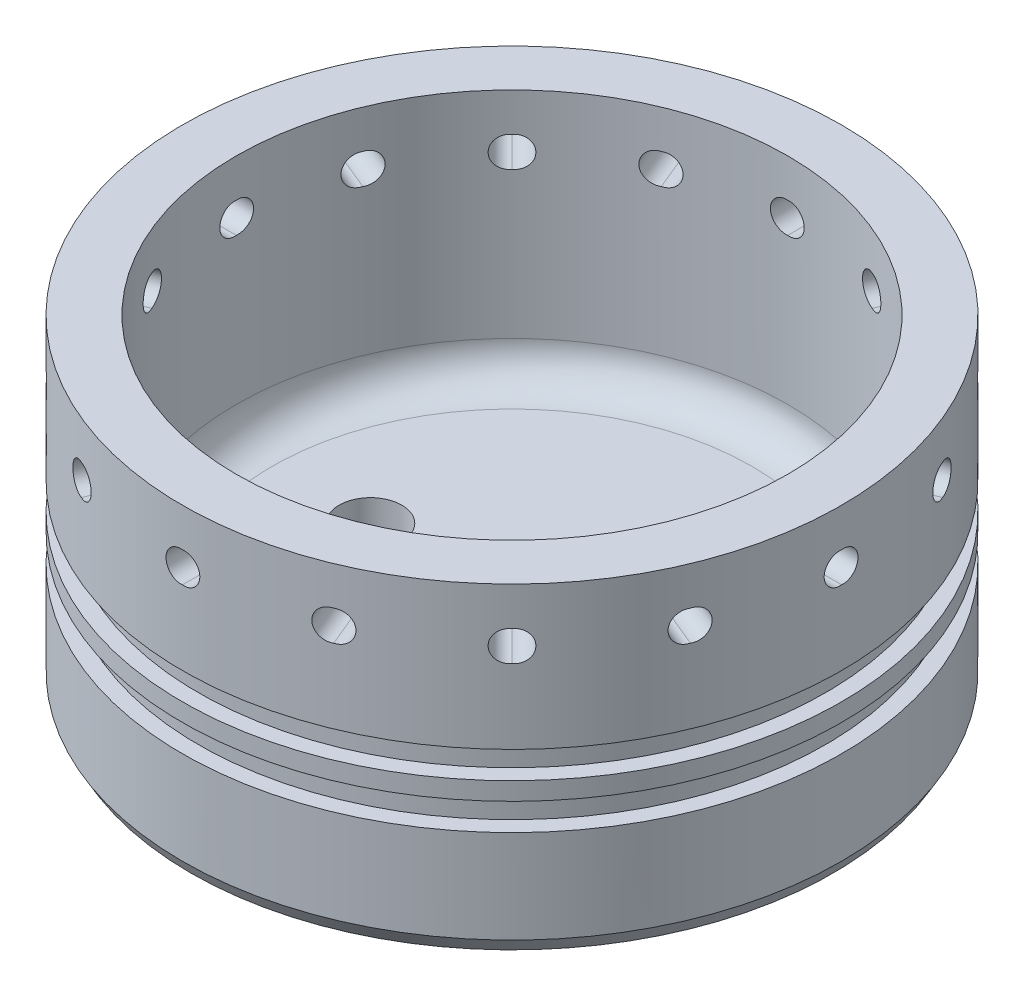
from build123d import *

# Parameters (mm, degrees)
FORWARDCLOSUREHOLES_D         = 5.4102
HOLEPATTERN_COUNT             = 16
CHAMFER1_SIZE                 = 2.54
CHAMFER1_SIZE2                = 1.466469684
FILLET1_R                     = 6.35
PIPE_TAP_DRILL_FOR_1_8_TAP1_D = 8.4328
PIPE_TAP_DRILL_FOR_1_4_TAP1_D = 11.1252


with BuildPart() as part:
    # Sketch1 → Revolve1 (revolve)
    with BuildSketch(Plane.XY):
        Polygon((0, 9.525), (0, -9.525), (58.4454, -9.525), (58.4454, 3.175), (9.525, 3.175), (9.525, 47.7012), (0, 47.7012), (0, 22.3012), (2.8194, 22.3012), (2.8194, 17.5006), (0, 17.5006), (0, 14.3256), (2.8194, 14.3256), (2.8194, 9.525), align=None)
    revolve(axis=Axis((58.4454, -9.525, 0), (0, 1, 0)))

    # ForwardClosureHoles (through all)
    with Locations(Plane.XY.offset(58.4454)):
        with Locations((58.7375, 38.1762)):
            forwardclosureholes = Hole(FORWARDCLOSUREHOLES_D / 2)

    # HolePattern: ForwardClosureHoles ×16 about axis
    holepattern_axis = Axis((58.4454, 47.7012, 0), (0, -1, 0))
    for i in range(1, HOLEPATTERN_COUNT):
        add(forwardclosureholes.rotate(holepattern_axis, i * 360 / HOLEPATTERN_COUNT), mode=Mode.SUBTRACT)

    # Chamfer1
    chamfer1_edges = [part.edges().sort_by_distance(p)[0] for p in [
        (116.8908, -9.525, 0),
    ]]
    chamfer1_side = [part.faces().sort_by_distance(p)[0] for p in [
        (116.8908, 0, 0),
    ]]
    chamfer(chamfer1_edges, length=CHAMFER1_SIZE, length2=CHAMFER1_SIZE2, reference=chamfer1_side[0])

    # Fillet1
    fillet1_edges = [part.edges().sort_by_distance(p)[0] for p in [
        (107.3658, 3.175, 0),
    ]]
    fillet(fillet1_edges, radius=FILLET1_R)

    # Pipe Tap Drill for 1/8 Tap1 (through all)
    with Locations(Plane(origin=(0, 3.175, 0), x_dir=(1, 0, 0), z_dir=(0, 1, 0))):
        with Locations((58.7375, 0)):
            Hole(PIPE_TAP_DRILL_FOR_1_8_TAP1_D / 2)

    # Pipe Tap Drill for 1/4 Tap1 (through all)
    with Locations(Plane(origin=(0, 3.175, 0), x_dir=(1, 0, 0), z_dir=(0, 1, 0))):
        with Locations((33.3375, 0)):
            Hole(PIPE_TAP_DRILL_FOR_1_4_TAP1_D / 2)


solid = part.part
